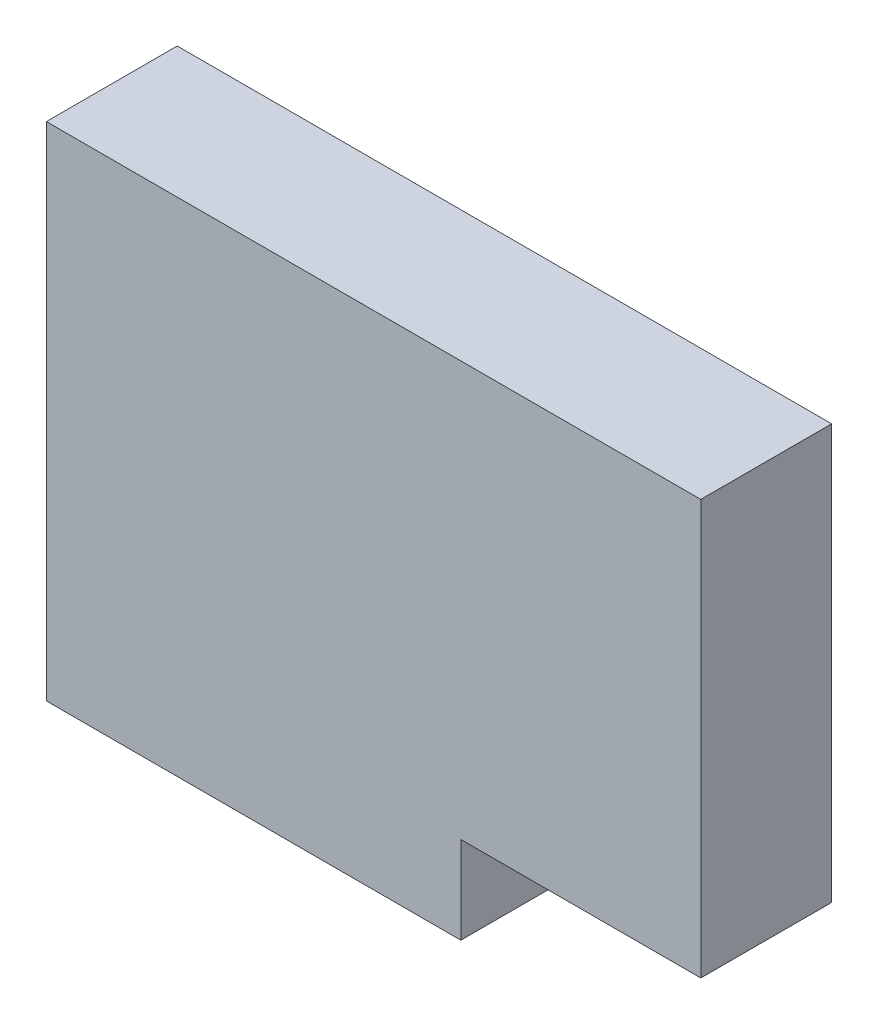
from build123d import *

# Parameters (mm, degrees)
SKETCH1_W           = 762
SKETCH1_H           = 584.2
BOSS_EXTRUDE1_DEPTH = 152.4
SKETCH2_W           = 279.4
SKETCH2_H           = 101.6
CUT_EXTRUDE1_DEPTH  = 152.4


with BuildPart() as part:
    # Sketch1 → Boss-Extrude1 (new body)
    with BuildSketch(Plane.XY):
        Rectangle(SKETCH1_W, SKETCH1_H)
    extrude(amount=BOSS_EXTRUDE1_DEPTH)

    # Sketch2 → Cut-Extrude1 (cut)
    with BuildSketch(Plane.XY.offset(152.4)):
        with Locations((241.3, -241.3)):
            Rectangle(SKETCH2_W, SKETCH2_H)
    extrude(amount=-CUT_EXTRUDE1_DEPTH, mode=Mode.SUBTRACT)


solid = part.part
